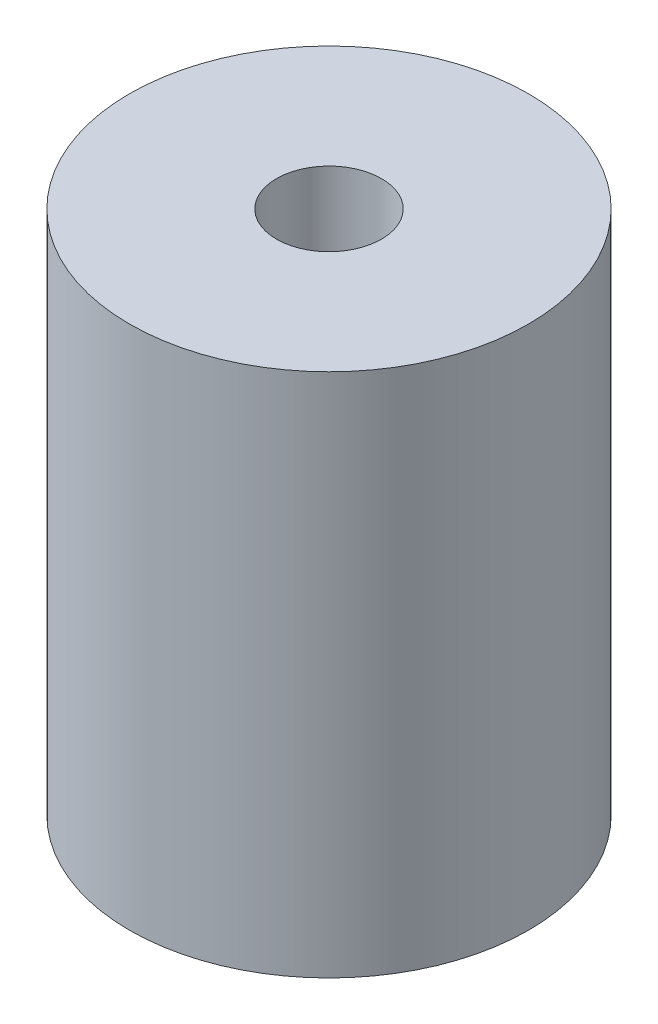
from build123d import *

# Parameters (mm, degrees)
SKETCH1_R           = 9.5
BOSS_EXTRUDE1_DEPTH = 25
SKETCH2_R           = 5
CUT_EXTRUDE1_DEPTH  = 10
SKETCH3_R           = 2.5
CUT_EXTRUDE2_DEPTH  = 26


with BuildPart() as part:
    # Sketch1 → Boss-Extrude1 (new body)
    with BuildSketch(Plane(origin=(0, 0, 0), x_dir=(1, 0, 0), z_dir=(0, 1, 0))):
        Circle(SKETCH1_R)
    extrude(amount=BOSS_EXTRUDE1_DEPTH)

    # Sketch2 → Cut-Extrude1 (cut)
    with BuildSketch(Plane.XZ):
        Circle(SKETCH2_R)
    extrude(amount=-CUT_EXTRUDE1_DEPTH, mode=Mode.SUBTRACT)

    # Sketch3 → Cut-Extrude2 (cut, through all)
    with BuildSketch(Plane(origin=(0, 25, 0), x_dir=(1, 0, 0), z_dir=(0, 1, 0))):
        Circle(SKETCH3_R)
    extrude(amount=-CUT_EXTRUDE2_DEPTH, mode=Mode.SUBTRACT)


solid = part.part
